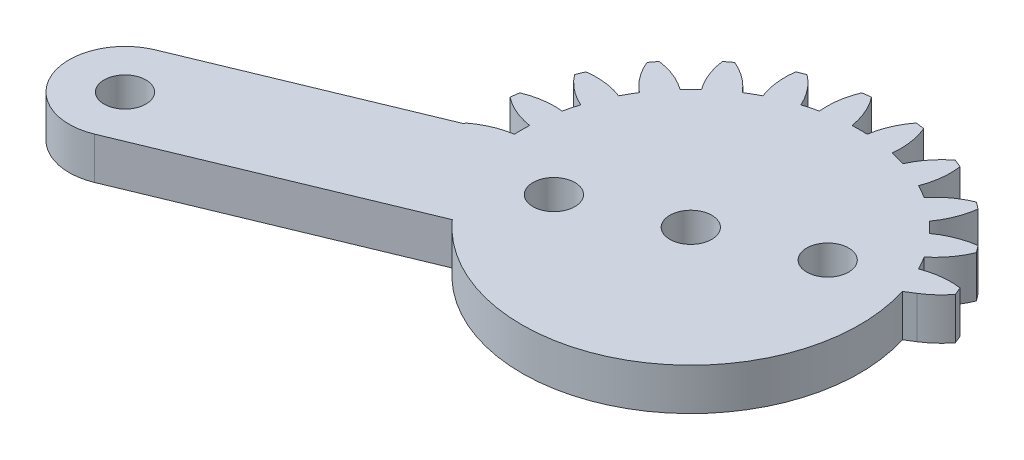
from build123d import *

# Parameters (mm, degrees)
SKETCH1_R           = 1.500000006
SKETCH1_R_2         = 1.5
BOSS_EXTRUDE1_DEPTH = 1.5


with BuildPart() as part:
    # Sketch1 → Boss-Extrude1 (new body, symmetric)
    with BuildSketch(Plane(origin=(0, 0, 0), x_dir=(1, 0, 0), z_dir=(0, 1, 0))):
        with BuildLine():
            Line((-9.06493699, -8.135610408), (-27.161854519, -15.631599086))
            ThreePointArc((-27.161854519, -15.631599086), (-32.388091388, -13.466808476), (-30.223321978, -8.240562826))
            Line((-30.223321978, -8.240562826), (-14.579602701, -1.760722136))
            ThreePointArc((-14.579602701, -1.760722136), (-14.584687893, -1.716362865), (-14.589637633, -1.671988275))
            ThreePointArc((-14.589637633, -1.671988275), (-13.427690306, -0.989315431), (-12.132887918, -0.615616914))
            ThreePointArc((-12.132887918, -0.615616914), (-12.145072741, -0.072894557), (-12.132887919, 0.469827801))
            ThreePointArc((-12.132887919, 0.469827801), (-13.427690307, 0.843526317), (-14.589637634, 1.526199162))
            ThreePointArc((-14.589637634, 1.526199162), (-14.55220384, 1.836051004), (-14.508166551, 2.14503348))
            ThreePointArc((-14.508166551, 2.14503348), (-13.209122885, 2.503710713), (-11.861719526, 2.529556244))
            ThreePointArc((-11.861719526, 2.529556244), (-11.733022279, 3.05693945), (-11.580785762, 3.578015328))
            ThreePointArc((-11.580785762, 3.578015328), (-12.734748535, 4.274099894), (-13.680414734, 5.234245323))
            ThreePointArc((-13.680414734, 5.234245323), (-13.564060907, 5.523850641), (-13.441553603, 5.810907105))
            ThreePointArc((-13.441553603, 5.810907105), (-12.093941278, 5.821145467), (-10.785760259, 5.497376682))
            ThreePointArc((-10.785760259, 5.497376682), (-10.524951446, 5.973480443), (-10.243037902, 6.437399381))
            ThreePointArc((-10.243037902, 6.437399381), (-11.177520404, 7.408432983), (-11.842459886, 8.580618673))
            ThreePointArc((-11.842459886, 8.580618673), (-11.655115347, 8.830241342), (-11.462486699, 9.075809372))
            ThreePointArc((-11.462486699, 9.075809372), (-10.158143266, 8.736911135), (-8.978334963, 8.085592341))
            ThreePointArc((-8.978334963, 8.085592341), (-8.603188274, 8.477970972), (-8.210809644, 8.853117661))
            ThreePointArc((-8.210809644, 8.853117661), (-8.862128438, 10.032925965), (-9.201026675, 11.337269397))
            ThreePointArc((-9.201026675, 11.337269397), (-8.955458646, 11.529898046), (-8.705835976, 11.717242585))
            ThreePointArc((-8.705835976, 11.717242585), (-7.533650287, 11.052303103), (-6.562616684, 10.117820601))
            ThreePointArc((-6.562616684, 10.117820601), (-6.098697746, 10.399734146), (-5.622593986, 10.66054296))
            ThreePointArc((-5.622593986, 10.66054296), (-5.946362771, 11.968723978), (-5.936124409, 13.316336304))
            ThreePointArc((-5.936124409, 13.316336304), (-5.649067945, 13.438843608), (-5.359462627, 13.555197435))
            ThreePointArc((-5.359462627, 13.555197435), (-4.399317198, 12.609531237), (-3.703232632, 11.455568464))
            ThreePointArc((-3.703232632, 11.455568464), (-3.182156754, 11.607804981), (-2.654773548, 11.736502229))
            ThreePointArc((-2.654773548, 11.736502229), (-2.628928016, 13.083905587), (-2.270250783, 14.382949252))
            ThreePointArc((-2.270250783, 14.382949252), (-1.961268307, 14.426986541), (-1.651416464, 14.464420335))
            ThreePointArc((-1.651416464, 14.464420335), (-0.96874362, 13.302473008), (-0.595045103, 12.007670621))
            ThreePointArc((-0.595045103, 12.007670621), (-0.052322745, 12.019855443), (0.490399612, 12.00767062))
            ThreePointArc((0.490399612, 12.00767062), (0.864098129, 13.302473008), (1.546770973, 14.464420336))
            ThreePointArc((1.546770973, 14.464420336), (1.856622816, 14.426986541), (2.165605292, 14.382949252))
            ThreePointArc((2.165605292, 14.382949252), (2.524282525, 13.083905586), (2.550128056, 11.736502227))
            ThreePointArc((2.550128056, 11.736502227), (3.077511262, 11.607804979), (3.59858714, 11.455568461))
            ThreePointArc((3.59858714, 11.455568461), (4.294671706, 12.609531235), (5.254817135, 13.555197433))
            ThreePointArc((5.254817135, 13.555197433), (5.544422453, 13.438843606), (5.831478917, 13.316336302))
            ThreePointArc((5.831478917, 13.316336302), (5.841717279, 11.968723977), (5.517948494, 10.660542958))
            ThreePointArc((5.517948494, 10.660542958), (5.994052255, 10.399734145), (6.457971192, 10.117820599))
            ThreePointArc((6.457971192, 10.117820599), (7.429004795, 11.052303102), (8.601190484, 11.717242583))
            ThreePointArc((8.601190484, 11.717242583), (8.850813154, 11.529898045), (9.096381183, 11.337269396))
            ThreePointArc((9.096381183, 11.337269396), (8.757482946, 10.032925964), (8.106164153, 8.85311766))
            ThreePointArc((8.106164153, 8.85311766), (8.498542783, 8.477970971), (8.873689471, 8.085592341))
            ThreePointArc((8.873689471, 8.085592341), (10.053497775, 8.736911134), (11.357841208, 9.075809372))
            ThreePointArc((11.357841208, 9.075809372), (11.550469856, 8.830241342), (11.737814395, 8.580618672))
            ThreePointArc((11.737814395, 8.580618672), (11.072874914, 7.408432983), (10.138392412, 6.437399381))
            ThreePointArc((10.138392412, 6.437399381), (10.420305956, 5.973480443), (10.681114769, 5.497376682))
            ThreePointArc((10.681114769, 5.497376682), (11.989295788, 5.821145468), (13.336908114, 5.810907106))
            ThreePointArc((13.336908114, 5.810907106), (13.459415418, 5.523850641), (13.575769244, 5.234245323))
            ThreePointArc((13.575769244, 5.234245323), (12.915048144, 4.515307178), (12.13566175, 3.927105445))
            Line((12.13566175, 3.927105445), (11.492100034, 3.52723119))
            ThreePointArc((11.492100034, 3.52723119), (5.914919678, -10.59081356), (-9.06493699, -8.135610408))
        make_face()
        with Locations((-0.052322747, -0.072894541)):
            Circle(SKETCH1_R, mode=Mode.SUBTRACT)
        with Locations((-28.692588249, -11.936080956)):
            Circle(SKETCH1_R_2, mode=Mode.SUBTRACT)
        with Locations((-6.981419235, -2.943020296)):
            Circle(SKETCH1_R_2, mode=Mode.SUBTRACT)
        with Locations((6.876773753, 2.79723119)):
            Circle(SKETCH1_R_2, mode=Mode.SUBTRACT)
    extrude(amount=BOSS_EXTRUDE1_DEPTH, both=True)


solid = part.part
